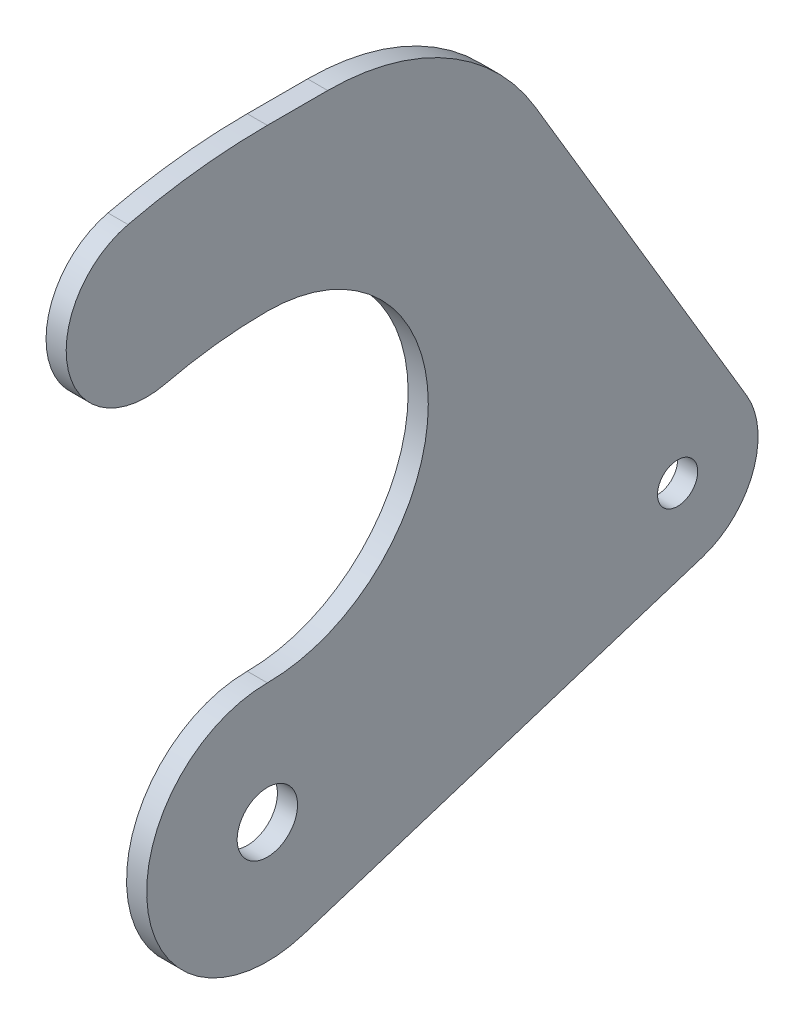
from build123d import *

# Parameters (mm, degrees)
SKETCH1_R           = 4.7625
SKETCH1_R_2         = 3.175
BOSS_EXTRUDE1_DEPTH = 3.175


with BuildPart() as part:
    # Sketch1 → Boss-Extrude1 (new body)
    with BuildSketch(Plane(origin=(0, 0, 0), x_dir=(0, 0, -1), z_dir=(1, 0, 0))):
        with BuildLine():
            Line((5.788160309, -18.149371896), (68.599953325, 1.882435781))
            ThreePointArc((68.599953325, 1.882435781), (76.614344046, 9.474471101), (75.657464978, 20.472372782))
            Line((75.657464978, 20.472372782), (42.273855579, 76.621067209))
            ThreePointArc((42.273855579, 76.621067209), (28.363289988, 90.266896448), (9.525, 95.25))
            Line((9.525, 95.25), (0, 95.25))
            ThreePointArc((0, 95.25), (-11.065305521, 94.60508186), (-21.980769231, 92.679060656))
            ThreePointArc((-21.980769231, 92.679060656), (-31.407208087, 77.391083338), (-16.119230769, 67.964644481))
            ThreePointArc((-16.119230769, 67.964644481), (-8.114557382, 69.377060031), (0, 69.85))
            ThreePointArc((0, 69.85), (25.4, 44.45), (0, 19.05))
            ThreePointArc((0, 19.05), (-18.823496416, -2.928904691), (5.788160309, -18.149371896))
        make_face()
        Circle(SKETCH1_R, mode=Mode.SUBTRACT)
        with Locations((64.741179785, 13.982017045)):
            Circle(SKETCH1_R_2, mode=Mode.SUBTRACT)
    extrude(amount=BOSS_EXTRUDE1_DEPTH)


solid = part.part
